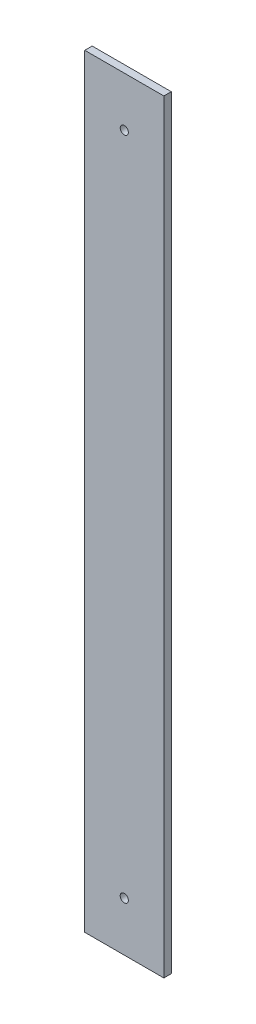
from build123d import *

# Parameters (mm, degrees)
ESQUISSE1_W             = 32
ESQUISSE1_H             = 309
BOSS_EXTRU_1_DEPTH      = 3
ESQUISSE2_R             = 1.65
ENL_V_MAT_EXTRU_1_DEPTH = 4


with BuildPart() as part:
    # Esquisse1 → Boss.-Extru.1 (new body)
    with BuildSketch(Plane.XY):
        with Locations((16, 154.5)):
            Rectangle(ESQUISSE1_W, ESQUISSE1_H)
    extrude(amount=BOSS_EXTRU_1_DEPTH)

    # Esquisse2 → Enlèv. mat.-Extru.1 (cut, through all)
    with BuildSketch(Plane.XY.offset(3)):
        with Locations((16, 289)):
            Circle(ESQUISSE2_R)
        with Locations((16, 20)):
            Circle(ESQUISSE2_R)
    extrude(amount=-ENL_V_MAT_EXTRU_1_DEPTH, mode=Mode.SUBTRACT)


solid = part.part
